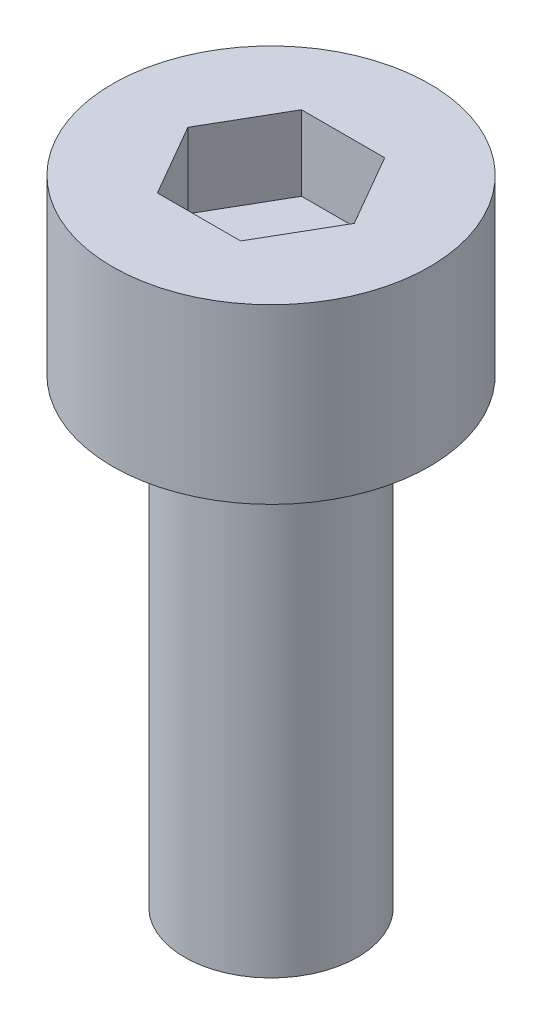
from build123d import *

# Parameters (mm, degrees)
SKETCH_1_R            = 2.75
EXTRUDE_248_DEPTH     = 3
CUT_EXTRUDE_378_DEPTH = 1.3
SKETCH_3_R            = 1.5
EXTRUDE_479_DEPTH     = 8


with BuildPart() as part:
    # 草图1 → Extrude 248 (new body)
    with BuildSketch(Plane(origin=(0, 0, 0), x_dir=(1, 0, 0), z_dir=(0, 1, 0))):
        Circle(SKETCH_1_R)
    extrude(amount=EXTRUDE_248_DEPTH)

    # 草图2 → Cut-Extrude 378 (cut)
    with BuildSketch(Plane(origin=(0, 3, 0), x_dir=(1, 0, 0), z_dir=(0, 1, 0))):
        Polygon((1.443375673, 0), (0.721687836, 1.25), (-0.721687836, 1.25), (-1.443375673, 0), (-0.721687836, -1.25), (0.721687836, -1.25), align=None)
    extrude(amount=-CUT_EXTRUDE_378_DEPTH, mode=Mode.SUBTRACT)

    # 草图3 → Extrude 479 (add)
    with BuildSketch(Plane.XZ):
        Circle(SKETCH_3_R)
    extrude(amount=EXTRUDE_479_DEPTH)


solid = part.part
